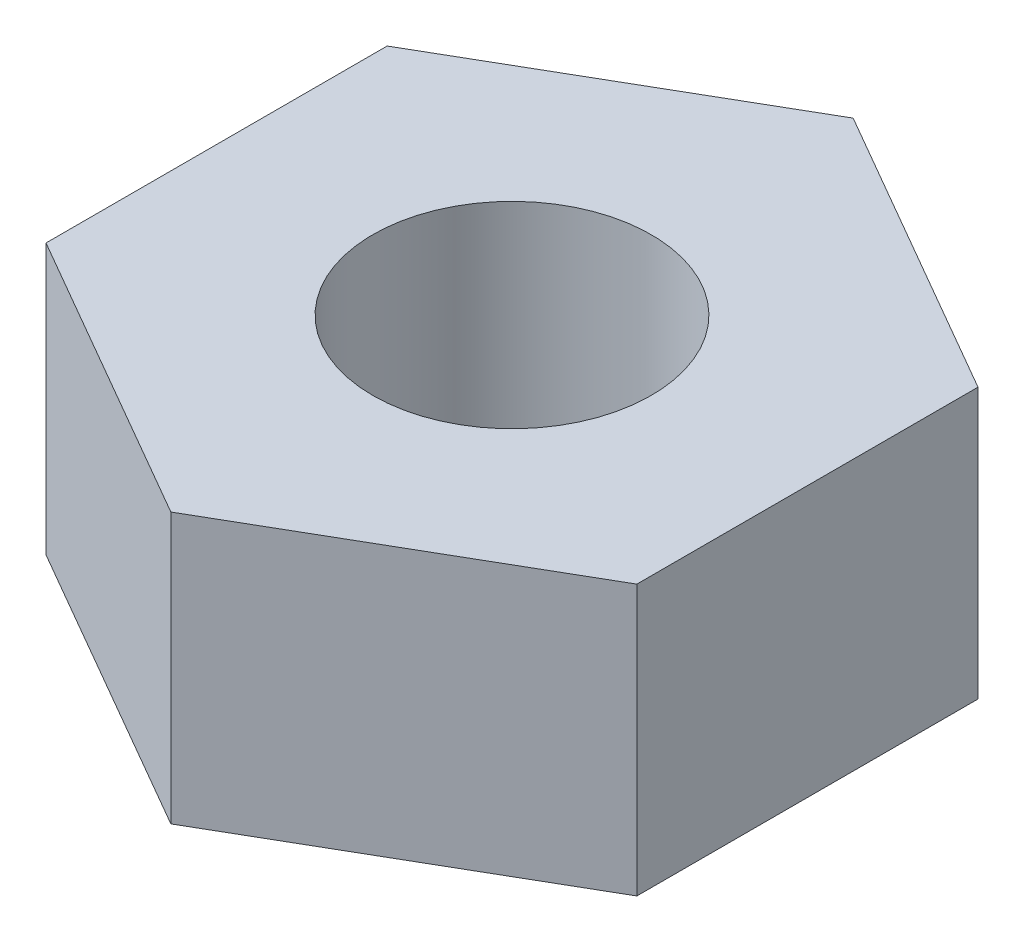
from build123d import *

# Parameters (mm, degrees)
EXTRUDE_1_DEPTH = 3.2
M4X0_71_D       = 3.3
M4X0_71_DEPTH   = 11.5
M4X0_71_TIP     = 0.991420021


with BuildPart() as part:
    # Эскиз1 → Бобышка-Вытянуть1 (new body)
    with BuildSketch(Plane(origin=(0, 0, 0), x_dir=(1, 0, 0), z_dir=(0, 1, 0))):
        Polygon((0, 4.041451884), (-3.5, 2.020725942), (-3.5, -2.020725942), (0, -4.041451884), (3.5, -2.020725942), (3.5, 2.020725942), align=None)
    extrude(amount=EXTRUDE_1_DEPTH)

    # Отверстие обработанное метчиком M4x0.71
    with Locations(Plane(origin=(0, 3.2, 0), x_dir=(1, 0, 0), z_dir=(0, 1, 0))):
        with Locations((0, 0)):
            Hole(M4X0_71_D / 2, depth=M4X0_71_DEPTH)
            with Locations((0, 0, -(M4X0_71_DEPTH + M4X0_71_TIP / 2))):  # 118° drill point
                Cone(0, M4X0_71_D / 2, M4X0_71_TIP, mode=Mode.SUBTRACT)


solid = part.part
